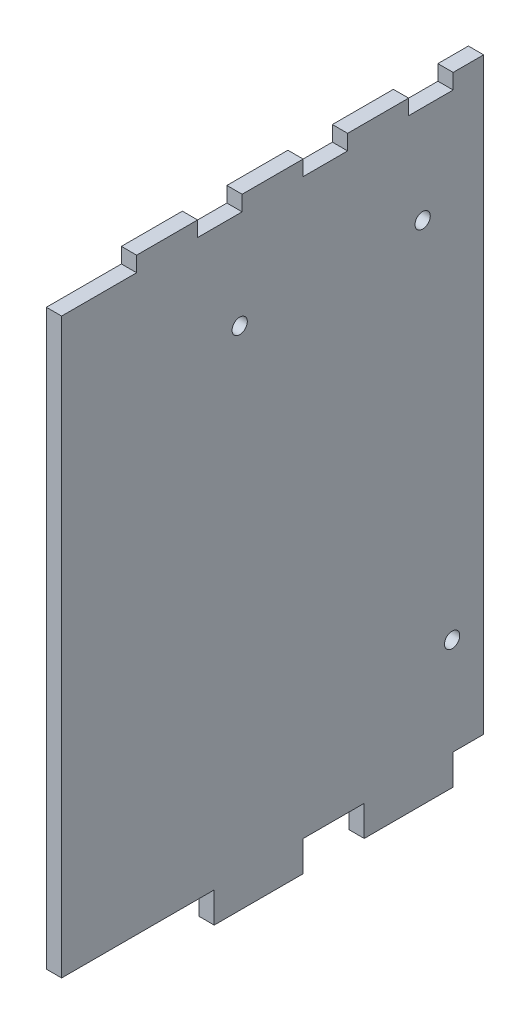
from build123d import *

# Parameters (mm, degrees)
BOSS_EXTRUDE1_DEPTH = 3.175
SKETCH2_R           = 1.5875
CUT_EXTRUDE1_DEPTH  = 4.175
SKETCH3_R           = 1.5875
CUT_EXTRUDE2_DEPTH  = 4.175


with BuildPart() as part:
    # Sketch1 → Boss-Extrude1 (new body)
    with BuildSketch(Plane(origin=(0, 0, 0), x_dir=(0, 0, -1), z_dir=(1, 0, 0))):
        Polygon((0, 119.38), (15.621, 119.38), (15.621, 122.555), (28.321, 122.555), (28.321, 119.38), (37.592, 119.38), (37.592, 122.555), (50.292, 122.555), (50.292, 119.38), (59.563, 119.38), (59.563, 122.555), (72.263, 122.555), (72.263, 119.38), (81.534, 119.38), (81.534, 122.555), (87.884, 122.555), (87.884, 0), (81.5086, 0), (81.5086, -6.35), (63.0174, -6.35), (63.0174, 0), (50.2666, 0), (50.2666, -6.35), (31.7754, -6.35), (31.7754, 0), (0, 0), align=None)
    extrude(amount=BOSS_EXTRUDE1_DEPTH)

    # Sketch2 → Cut-Extrude1 (cut, through all)
    with BuildSketch(Plane(origin=(3.175, 0, 0), x_dir=(0, 0, -1), z_dir=(1, 0, 0))):
        with Locations((37.084, 99.06)):
            Circle(SKETCH2_R)
        with Locations((75.184, 99.06)):
            Circle(SKETCH2_R)
    extrude(amount=-CUT_EXTRUDE1_DEPTH, mode=Mode.SUBTRACT)

    # Sketch3 → Cut-Extrude2 (cut, through all)
    with BuildSketch(Plane.ZY):
        with Locations((-81.319973634, 20.32)):
            Circle(SKETCH3_R)
    extrude(amount=-CUT_EXTRUDE2_DEPTH, mode=Mode.SUBTRACT)


solid = part.part
